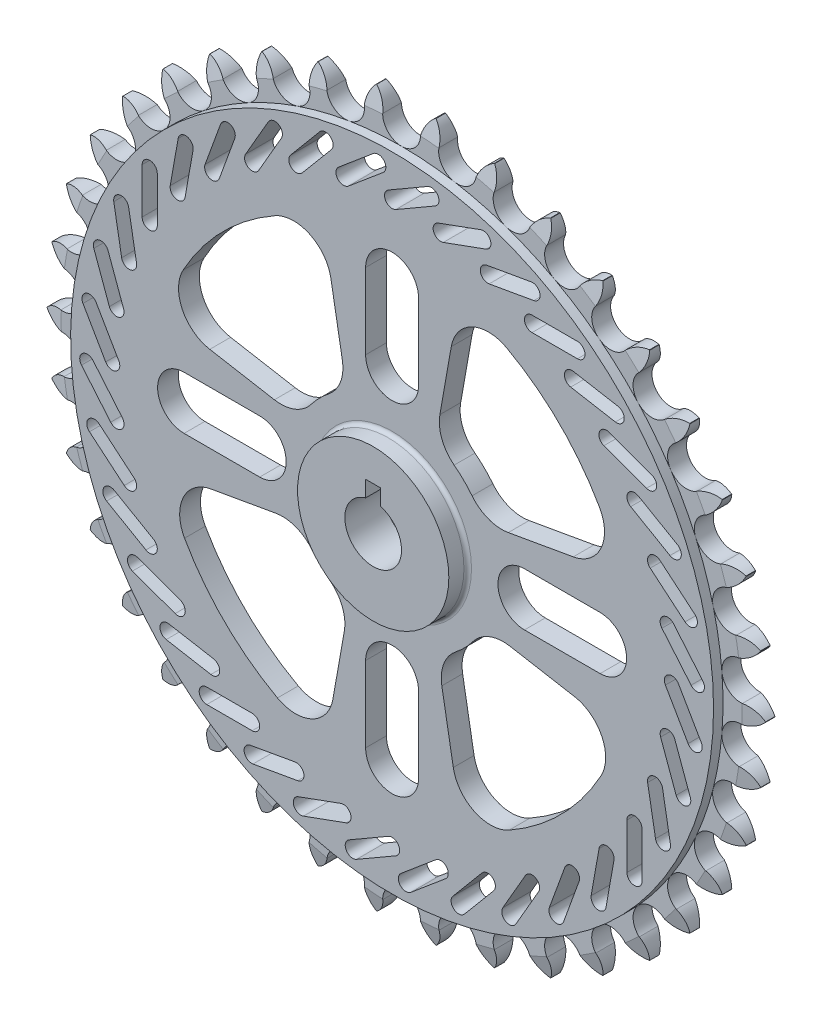
from build123d import *

# Parameters (mm, degrees)
SKETCH1_R               = 95
BOSS_EXTRUDE1_DEPTH     = 2.5
SKETCH2_R               = 85
BOSS_EXTRUDE2_DEPTH     = 2.5
CUT_EXTRUDE1_DEPTH      = 8.5
CIRPATTERN1_COUNT       = 38
CUT_EXTRUDE2_DEPTH      = 8.5000001
CIRPATTERN2_COUNT       = 36
CUT_EXTRUDE3_DEPTH      = 8.5000001
CIRPATTERN3_COUNT       = 4
CUT_EXTRUDE4_DEPTH      = 8.5000001
CIRPATTERN4_COUNT       = 4
SKETCH10_R              = 7.5
CUT_EXTRUDE5_DEPTH      = 6
CUT_EXTRUDE5_DEPTH_BACK = 3.5000001
SKETCH11_R              = 20
SKETCH11_R_2            = 7.5
BOSS_EXTRUDE3_DEPTH     = 10
FILLET1_R               = 1
SKETCH12_W              = 4
SKETCH12_H              = 8
CUT_EXTRUDE6_DEPTH      = 1
CUT_EXTRUDE6_DEPTH_BACK = 13.5000001
SKETCH14_R              = 70
CUT_EXTRUDE7_DEPTH      = 2
FILLET2_R               = 1


with BuildPart() as part:
    # Sketch1 → Boss-Extrude1 (new body, symmetric)
    with BuildSketch(Plane.XY):
        Circle(SKETCH1_R)
    extrude(amount=BOSS_EXTRUDE1_DEPTH, both=True)

    # Sketch2 → Boss-Extrude2 (add)
    with BuildSketch(Plane.XY.offset(2.5)):
        Circle(SKETCH2_R)
    extrude(amount=BOSS_EXTRUDE2_DEPTH)

    # Sketch4 → Cut-Revolve1 (revolve, cut)
    with BuildSketch(Plane(origin=(0, 0, 0), x_dir=(0, 0, -1), z_dir=(1, 0, 0))):
        Polygon((-2.5, 90), (0, 100), (2.5, 90), (7.5, 90), (7.5, 105), (-7.5, 105), (-7.5, 90), align=None)
    revolve(axis=Axis((0, 0, 0), (0, 0, -1)), mode=Mode.SUBTRACT)

    # Sketch6 → Cut-Extrude1 (cut, through all)
    with BuildSketch(Plane.XY.offset(5)):
        with BuildLine():
            ThreePointArc((7.797853893, 94.679424769), (5.938008369, 92.615298146), (5, 90))
            ThreePointArc((5, 90), (0, 85), (-5, 90))
            ThreePointArc((-5, 90), (-5.938008369, 92.615298146), (-7.797853893, 94.679424769))
            ThreePointArc((-7.797853893, 94.679424769), (0, 97.909401609), (7.797853893, 94.679424769))
        make_face()
    cut_extrude1 = extrude(amount=-CUT_EXTRUDE1_DEPTH, mode=Mode.SUBTRACT)

    # CirPattern1: Cut-Extrude1 ×38 about axis
    cirpattern1_axis = Axis((0, 0, 0), (0, 0, 1))
    for i in range(1, CIRPATTERN1_COUNT):
        add(cut_extrude1.rotate(cirpattern1_axis, i * 360 / CIRPATTERN1_COUNT), mode=Mode.SUBTRACT)

    # Sketch7 → Cut-Extrude2 (cut, through all)
    with BuildSketch(Plane.XY.offset(5)):
        with BuildLine():
            Line((-1, 75.732050808), (9.392304845, 81.732050808))
            ThreePointArc((9.392304845, 81.732050808), (12.124355653, 81), (11.392304845, 78.267949192))
            Line((11.392304845, 78.267949192), (1, 72.267949192))
            ThreePointArc((1, 72.267949192), (-1.732050808, 73), (-1, 75.732050808))
        make_face()
    cut_extrude2 = extrude(amount=-CUT_EXTRUDE2_DEPTH, mode=Mode.SUBTRACT)

    # CirPattern2: Cut-Extrude2 ×36 about axis
    cirpattern2_axis = Axis((0, 0, 0), (0, 0, 1))
    for i in range(1, CIRPATTERN2_COUNT):
        add(cut_extrude2.rotate(cirpattern2_axis, i * 360 / CIRPATTERN2_COUNT), mode=Mode.SUBTRACT)

    # Sketch8 → Cut-Extrude3 (cut, through all)
    with BuildSketch(Plane.XY.offset(5)):
        with BuildLine():
            Line((7, 55), (7, 35))
            ThreePointArc((7, 35), (0, 28), (-7, 35))
            Line((-7, 35), (-7, 55))
            ThreePointArc((-7, 55), (0, 62), (7, 55))
        make_face()
    cut_extrude3 = extrude(amount=-CUT_EXTRUDE3_DEPTH, mode=Mode.SUBTRACT)

    # CirPattern3: Cut-Extrude3 ×4 about axis
    cirpattern3_axis = Axis((0, 0, 0), (0, 0, 1))
    for i in range(1, CIRPATTERN3_COUNT):
        add(cut_extrude3.rotate(cirpattern3_axis, i * 360 / CIRPATTERN3_COUNT), mode=Mode.SUBTRACT)

    # Sketch9 → Cut-Extrude4 (cut, through all)
    with BuildSketch(Plane.XY.offset(5)):
        with BuildLine():
            Line((-48.199815219, 15.650131142), (-31.119441313, 12.638400382))
            ThreePointArc((-31.119441313, 12.638400382), (-25.752598666, 13.168727113), (-21.441619121, 16.409051449))
            ThreePointArc((-21.441619121, 16.409051449), (-19.259093828, 18.923194892), (-16.783736947, 21.149614041))
            ThreePointArc((-16.783736947, 21.149614041), (-13.650609617, 25.434551389), (-13.151858286, 30.719286203))
            Line((-13.151858286, 30.719286203), (-16.181980041, 47.903960621))
            ThreePointArc((-16.181980041, 47.903960621), (-21.757669378, 55.208866964), (-30.941389188, 54.878323909))
            ThreePointArc((-30.941389188, 54.878323909), (-44.802763886, 44.291222022), (-55.230000129, 30.30919144))
            ThreePointArc((-55.230000129, 30.30919144), (-55.480042604, 21.173979737), (-48.199815219, 15.650131142))
        make_face()
    cut_extrude4 = extrude(amount=-CUT_EXTRUDE4_DEPTH, mode=Mode.SUBTRACT)

    # CirPattern4: Cut-Extrude4 ×4 about axis
    cirpattern4_axis = Axis((0, 0, 0), (0, 0, 1))
    for i in range(1, CIRPATTERN4_COUNT):
        add(cut_extrude4.rotate(cirpattern4_axis, i * 360 / CIRPATTERN4_COUNT), mode=Mode.SUBTRACT)

    # Sketch10 → Cut-Extrude5 (cut, two sides)
    with BuildSketch(Plane.XY) as cut_extrude5_sk:
        Circle(SKETCH10_R)
    extrude(amount=CUT_EXTRUDE5_DEPTH, mode=Mode.SUBTRACT)
    extrude(cut_extrude5_sk.sketch, amount=-CUT_EXTRUDE5_DEPTH_BACK, mode=Mode.SUBTRACT)

    # Sketch11 → Boss-Extrude3 (add)
    with BuildSketch(Plane.XY):
        Circle(SKETCH11_R)
        Circle(SKETCH11_R_2, mode=Mode.SUBTRACT)
    extrude(amount=BOSS_EXTRUDE3_DEPTH)

    # Fillet1
    fillet1_edges = [part.edges().sort_by_distance(p)[0] for p in [
        (-20, 0, 5),
    ]]
    fillet(fillet1_edges, radius=FILLET1_R)

    # Sketch12 → Cut-Extrude6 (cut, two sides)
    with BuildSketch(Plane.XY.offset(10)) as cut_extrude6_sk:
        with Locations((0, 7.5)):
            Rectangle(SKETCH12_W, SKETCH12_H)
    extrude(amount=CUT_EXTRUDE6_DEPTH, mode=Mode.SUBTRACT)
    extrude(cut_extrude6_sk.sketch, amount=-CUT_EXTRUDE6_DEPTH_BACK, mode=Mode.SUBTRACT)

    # Sketch14 → Cut-Extrude7 (cut)
    with BuildSketch(Plane(origin=(0, 0, -2.5), x_dir=(-1, 0, 0), z_dir=(0, 0, -1))):
        Circle(SKETCH14_R)
    extrude(amount=-CUT_EXTRUDE7_DEPTH, mode=Mode.SUBTRACT)

    # Fillet2
    fillet2_edges = [part.edges().sort_by_distance(p)[0] for p in [
        (70, 0, -0.5),
    ]]
    fillet(fillet2_edges, radius=FILLET2_R)


solid = part.part
